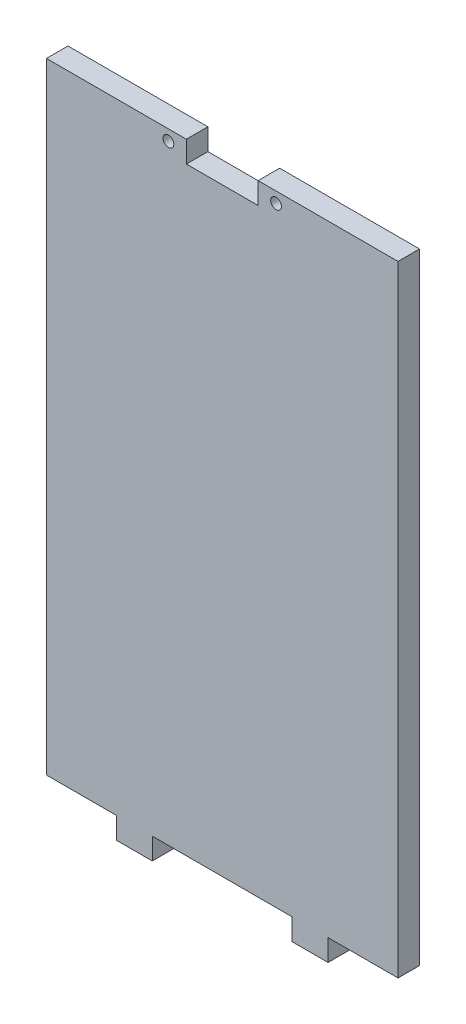
from build123d import *

# Parameters (mm, degrees)
ESQUISSE1_W             = 98
ESQUISSE1_H             = 173
BOSS_EXTRU_1_DEPTH      = 6
ESQUISSE2_W             = 10
ESQUISSE2_H             = 6
BOSS_EXTRU_2_DEPTH      = 6
ESQUISSE3_R             = 1.5
ENL_V_MAT_EXTRU_1_DEPTH = 6
ESQUISSE4_W             = 20
ESQUISSE4_H             = 6
ENL_V_MAT_EXTRU_2_DEPTH = 6


with BuildPart() as part:
    # Esquisse1 → Boss.-Extru.1 (new body)
    with BuildSketch(Plane.XY):
        Rectangle(ESQUISSE1_W, ESQUISSE1_H)
    extrude(amount=BOSS_EXTRU_1_DEPTH)

    # Esquisse2 → Boss.-Extru.2 (add)
    with BuildSketch(Plane.XY.offset(6)):
        with Locations((24.5, -89.5)):
            Rectangle(ESQUISSE2_W, ESQUISSE2_H)
        with Locations((-24.5, -89.5)):
            Rectangle(ESQUISSE2_W, ESQUISSE2_H)
    extrude(amount=-BOSS_EXTRU_2_DEPTH)

    # Esquisse3 → Enlèv. mat.-Extru.1 (cut)
    with BuildSketch(Plane.XY.offset(6)):
        with Locations((-15, 83.5)):
            Circle(ESQUISSE3_R)
        with Locations((15, 83.5)):
            Circle(ESQUISSE3_R)
    extrude(amount=-ENL_V_MAT_EXTRU_1_DEPTH, mode=Mode.SUBTRACT)

    # Esquisse4 → Enlèv. mat.-Extru.2 (cut)
    with BuildSketch(Plane.XY.offset(6)):
        with Locations((0, 83.5)):
            Rectangle(ESQUISSE4_W, ESQUISSE4_H)
    extrude(amount=-ENL_V_MAT_EXTRU_2_DEPTH, mode=Mode.SUBTRACT)


solid = part.part
